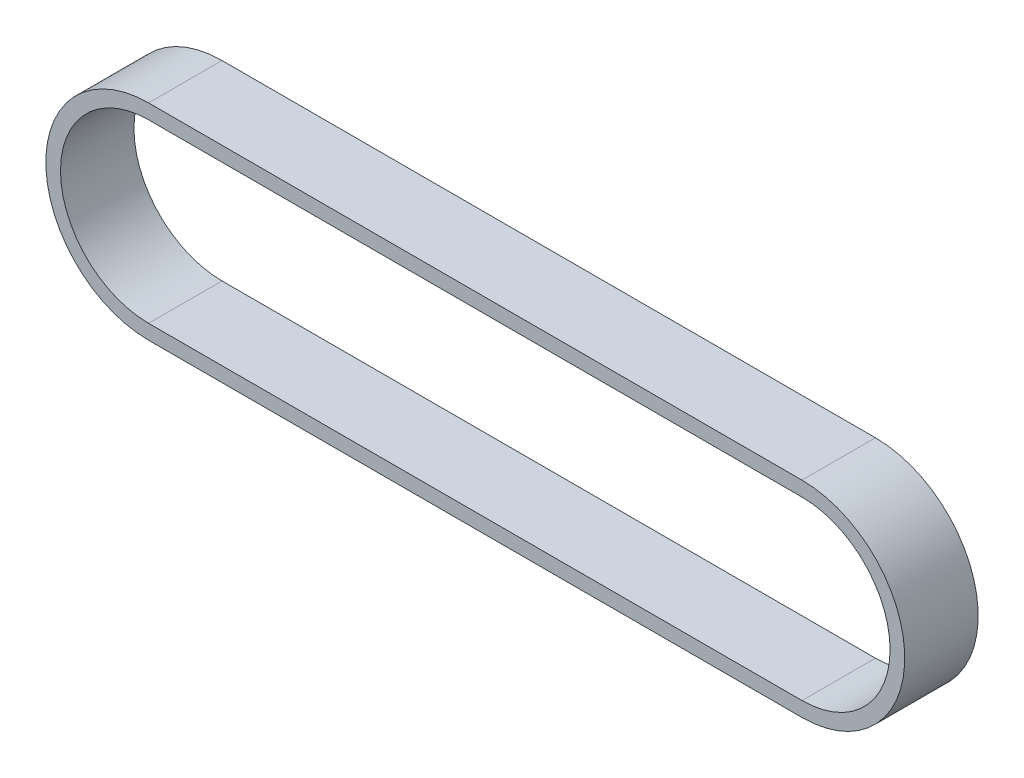
from build123d import *

# Parameters (mm, degrees)
EXTRUDE_1_DEPTH = 10


with BuildPart() as part:
    # 草图1 → 凸台-拉伸1 (new body)
    with BuildSketch(Plane.XY):
        with BuildLine():
            Line((0, 14), (89, 14))
            ThreePointArc((89, 14), (103, 0), (89, -14))
            Line((89, -14), (0, -14))
            ThreePointArc((0, -14), (-14, 0), (0, 14))
        make_face()
        with BuildLine():
            Line((0, 12), (89, 12))
            ThreePointArc((89, 12), (101, 0), (89, -12))
            Line((89, -12), (0, -12))
            ThreePointArc((0, -12), (-12, 0), (0, 12))
        make_face(mode=Mode.SUBTRACT)
    extrude(amount=EXTRUDE_1_DEPTH)


solid = part.part
